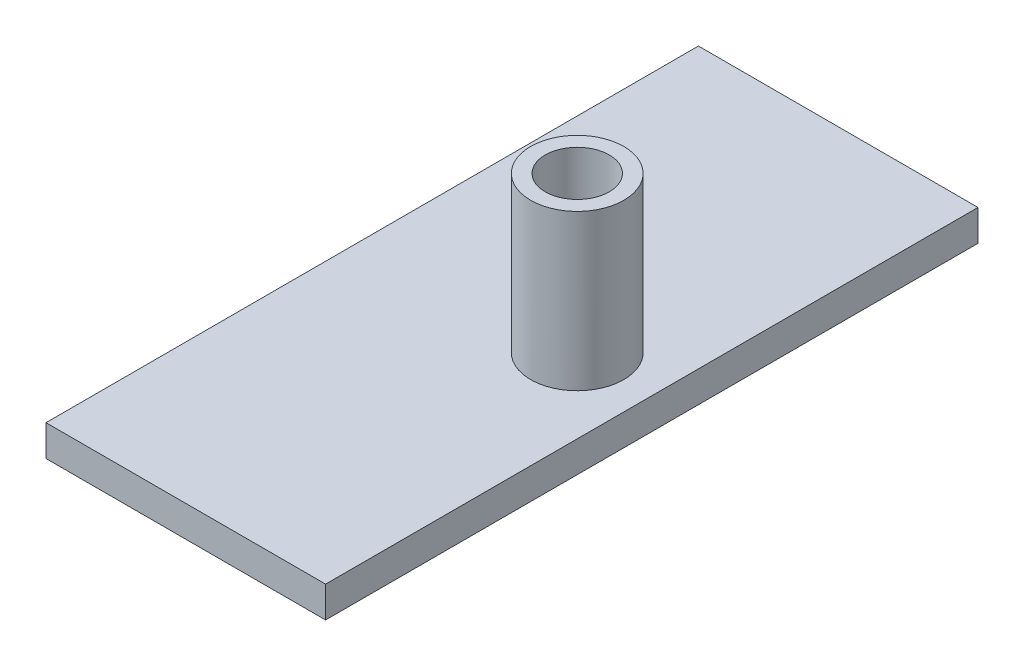
from build123d import *

# Parameters (mm, degrees)
SKETCH1_W           = 45
SKETCH1_H           = 105
BOSS_EXTRUDE3_DEPTH = 5
SKETCH3_R           = 7.5
BOSS_EXTRUDE4_DEPTH = 25
SKETCH4_R           = 5.15
CUT_EXTRUDE1_DEPTH  = 20


with BuildPart() as part:
    # Sketch1 → Boss-Extrude3 (new body)
    with BuildSketch(Plane(origin=(0, 0, 0), x_dir=(1, 0, 0), z_dir=(0, 1, 0))):
        with Locations((22.5, 52.5)):
            Rectangle(SKETCH1_W, SKETCH1_H)
    extrude(amount=BOSS_EXTRUDE3_DEPTH)

    # Sketch3 → Boss-Extrude4 (add)
    with BuildSketch(Plane(origin=(0, 5, 0), x_dir=(1, 0, 0), z_dir=(0, 1, 0))):
        with Locations((33, 52.5)):
            Circle(SKETCH3_R)
    extrude(amount=BOSS_EXTRUDE4_DEPTH)

    # Sketch4 → Cut-Extrude1 (cut)
    with BuildSketch(Plane(origin=(0, 30, 0), x_dir=(1, 0, 0), z_dir=(0, 1, 0))):
        with Locations((33, 52.5)):
            Circle(SKETCH4_R)
    extrude(amount=-CUT_EXTRUDE1_DEPTH, mode=Mode.SUBTRACT)


solid = part.part
